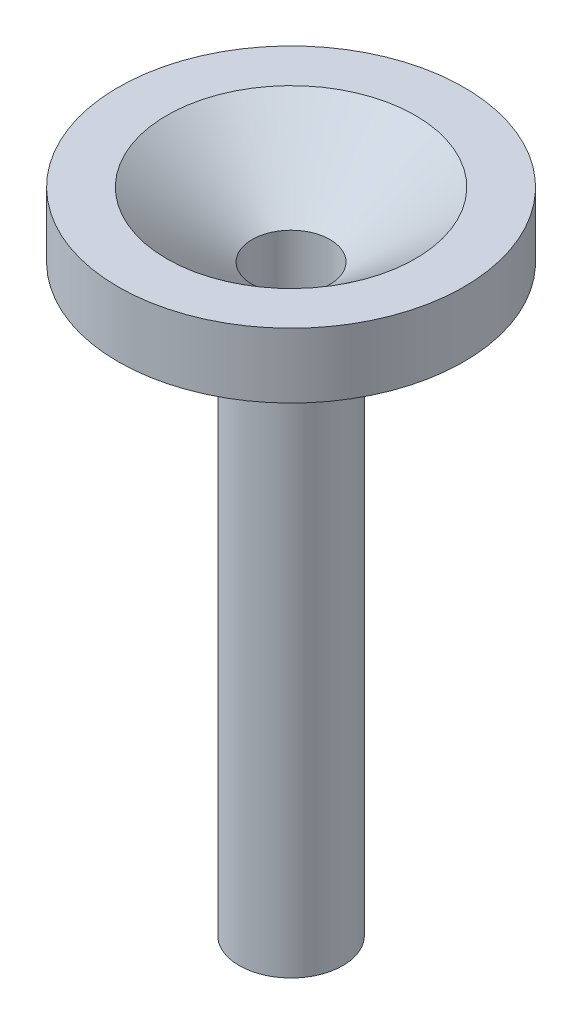
from build123d import *


with BuildPart() as part:
    # Sketch1 → Revolve1 (revolve)
    with BuildSketch(Plane.XY):
        Polygon((9, -113.730769231), (9, 16.269230769), (28.75, 31.269230769), (40, 31.269230769), (40, 16.269230769), (12, 16.269230769), (12, -118.730769231), (10.5, -118.730769231), (10.5, -113.730769231), align=None)
    revolve(axis=Axis((0, 35.081305491, 0), (0, -1, 0)))


solid = part.part
